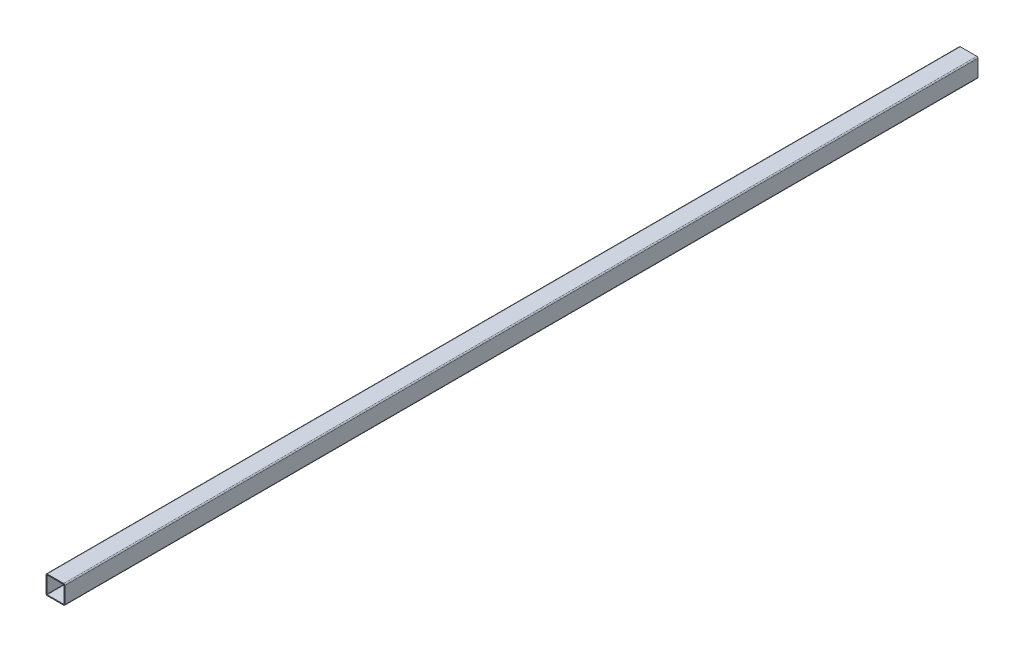
from build123d import *

# Parameters (mm, degrees)
BOSS_EXTRUDE1_DEPTH      = 774
BOSS_EXTRUDE1_DEPTH_BACK = 774


with BuildPart() as part:
    # Sketch1 → Boss-Extrude1 (new, two sides: drawn at the far end of the back side and taken through both)
    with BuildSketch(Plane.XY.offset(-BOSS_EXTRUDE1_DEPTH_BACK)):
        with BuildLine():
            Line((-14, -16), (14, -16))
            ThreePointArc((14, -16), (15.414213562, -15.414213562), (16, -14))
            Line((16, -14), (16, 14))
            ThreePointArc((16, 14), (15.414213562, 15.414213562), (14, 16))
            Line((14, 16), (-14, 16))
            ThreePointArc((-14, 16), (-15.414213562, 15.414213562), (-16, 14))
            Line((-16, 14), (-16, -14))
            ThreePointArc((-16, -14), (-15.414213562, -15.414213562), (-14, -16))
        make_face()
        with BuildLine():
            Line((-14, 14.48), (14, 14.48))
            ThreePointArc((14, 14.48), (14.339411255, 14.339411255), (14.48, 14))
            Line((14.48, 14), (14.48, -14))
            ThreePointArc((14.48, -14), (14.339411255, -14.339411255), (14, -14.48))
            Line((14, -14.48), (-14, -14.48))
            ThreePointArc((-14, -14.48), (-14.339411255, -14.339411255), (-14.48, -14))
            Line((-14.48, -14), (-14.48, 14))
            ThreePointArc((-14.48, 14), (-14.339411255, 14.339411255), (-14, 14.48))
        make_face(mode=Mode.SUBTRACT)
    extrude(amount=BOSS_EXTRUDE1_DEPTH + BOSS_EXTRUDE1_DEPTH_BACK)


solid = part.part
